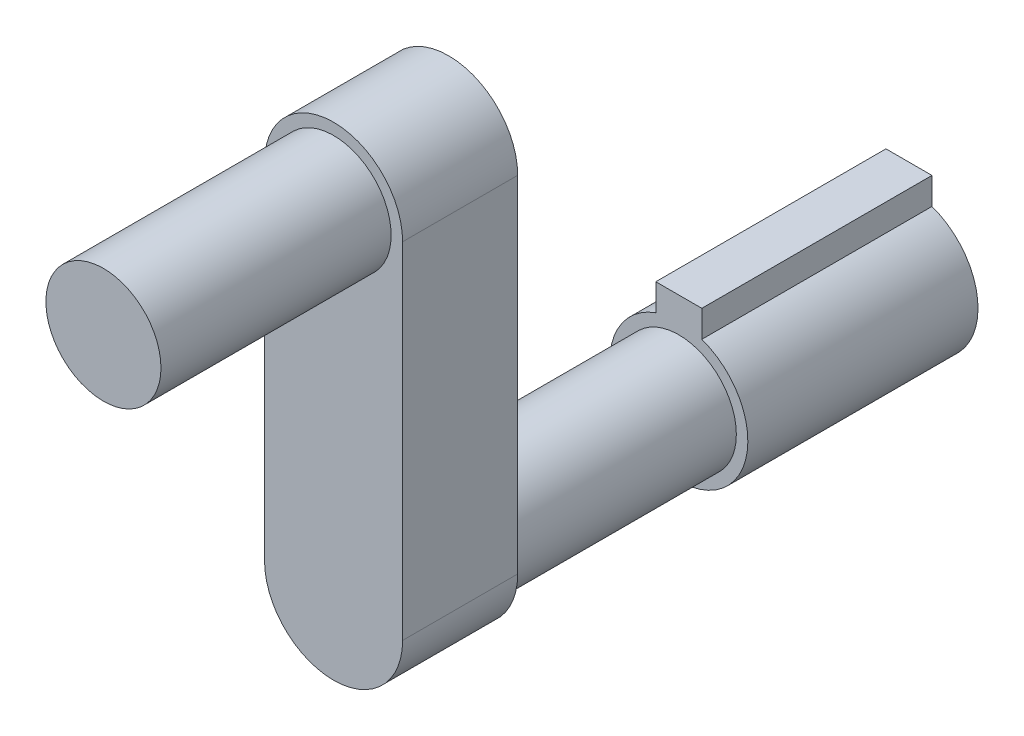
from build123d import *

# Parameters (mm, degrees)
SKETCH1_R           = 3
SKETCH1_W           = 2
SKETCH1_H           = 1.993597438
BOSS_EXTRUDE1_DEPTH = 10
SKETCH2_R           = 2.5
BOSS_EXTRUDE2_DEPTH = 10
BOSS_EXTRUDE3_DEPTH = 5
SKETCH4_R           = 2.5
BOSS_EXTRUDE4_DEPTH = 10


with BuildPart() as part:
    # Sketch1 → Boss-Extrude1 (new body)
    with BuildSketch(Plane.XY):
        Circle(SKETCH1_R)
        with Locations((0, 3)):
            Rectangle(SKETCH1_W, SKETCH1_H)
    extrude(amount=BOSS_EXTRUDE1_DEPTH)

    # Sketch2 → Boss-Extrude2 (add)
    with BuildSketch(Plane.XY.offset(10)):
        Circle(SKETCH2_R)
    extrude(amount=BOSS_EXTRUDE2_DEPTH)

    # Sketch3 → Boss-Extrude3 (add)
    with BuildSketch(Plane.XY.offset(20)):
        with BuildLine():
            Line((-3, 0), (-3, 15))
            ThreePointArc((-3, 15), (0, 18), (3, 15))
            Line((3, 15), (3, 0))
            ThreePointArc((3, 0), (0, -3), (-3, 0))
        make_face()
    extrude(amount=BOSS_EXTRUDE3_DEPTH)

    # Sketch4 → Boss-Extrude4 (add)
    with BuildSketch(Plane.XY.offset(25)):
        with Locations((0, 15)):
            Circle(SKETCH4_R)
    extrude(amount=BOSS_EXTRUDE4_DEPTH)


solid = part.part
